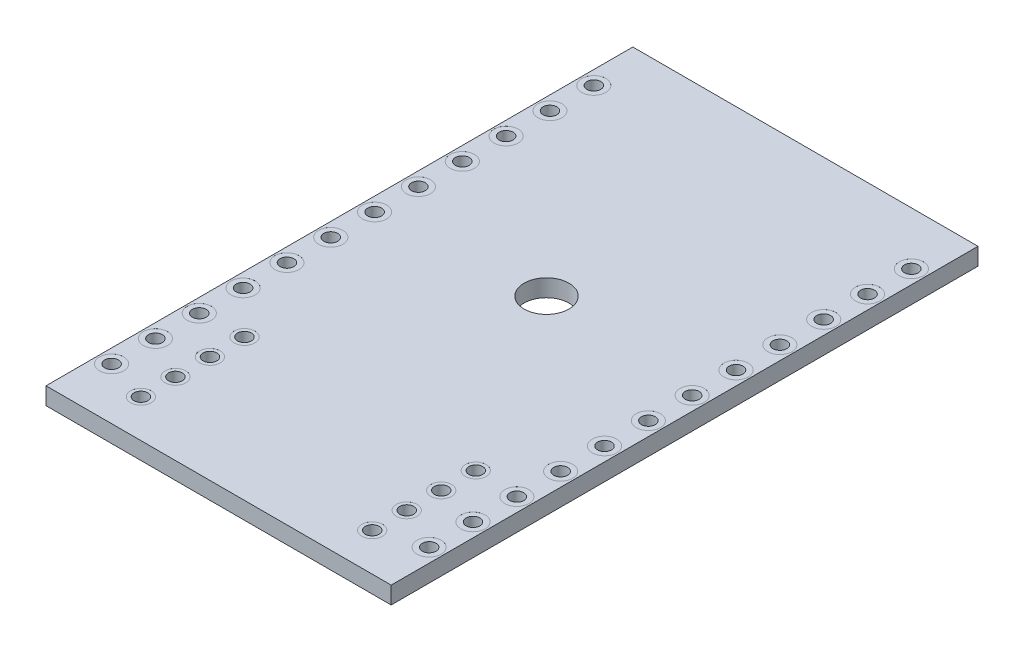
from build123d import *

# Parameters (mm, degrees)
BASES_W                        = 20
BASES_H                        = 34
BASE_DEPTH                     = 0.5
FASTENINGHOLES_R               = 1.3
FASTENINGHOLE_DEPTH            = 2
F_0_8_0_8_DIAMETER_HOLE1_D     = 0.8
SOLDERACCESSCUTS_R             = 0.7
SOLDERACCESSCUT_DEPTH          = 0.001
HOLESACHORZLP_COUNT            = 12
HOLESACHORZLP_PITCH            = 2.54
HOLESACHORZLP_COPY_1_SKETCH_R  = 0.7
HOLESACHORZLP_COPY_1_DEPTH     = 0.001
HOLESACHORZLP_COPY_2_SKETCH_R  = 0.7
HOLESACHORZLP_COPY_2_DEPTH     = 0.001
HOLESACHORZLP_COPY_3_SKETCH_R  = 0.7
HOLESACHORZLP_COPY_3_DEPTH     = 0.001
HOLESACHORZLP_COPY_4_SKETCH_R  = 0.7
HOLESACHORZLP_COPY_4_DEPTH     = 0.001
HOLESACHORZLP_COPY_5_SKETCH_R  = 0.7
HOLESACHORZLP_COPY_5_DEPTH     = 0.001
HOLESACHORZLP_COPY_6_SKETCH_R  = 0.7
HOLESACHORZLP_COPY_6_DEPTH     = 0.001
HOLESACHORZLP_COPY_7_SKETCH_R  = 0.7
HOLESACHORZLP_COPY_7_DEPTH     = 0.001
HOLESACHORZLP_COPY_8_SKETCH_R  = 0.7
HOLESACHORZLP_COPY_8_DEPTH     = 0.001
HOLESACHORZLP_COPY_9_SKETCH_R  = 0.7
HOLESACHORZLP_COPY_9_DEPTH     = 0.001
HOLESACHORZLP_COPY_10_SKETCH_R = 0.7
HOLESACHORZLP_COPY_10_DEPTH    = 0.001
HOLESACHORZLP_COPY_11_SKETCH_R = 0.7
HOLESACHORZLP_COPY_11_DEPTH    = 0.001
HSHM_COPY_1_D                  = 0.8
HSHM_COPY_2_D                  = 0.8
HSHM_COPY_3_D                  = 0.8
HSHM_COPY_4_D                  = 0.8
HSHM_COPY_5_D                  = 0.8
HSHM_COPY_6_D                  = 0.8
HSHM_COPY_7_D                  = 0.8
HSHM_COPY_8_D                  = 0.8
HSHM_COPY_9_D                  = 0.8
HSHM_COPY_10_D                 = 0.8
HSHM_COPY_11_D                 = 0.8
HSHM_COPY_12_SKETCH_R          = 0.7
HSHM_COPY_12_DEPTH             = 0.001
HSHM_COPY_13_SKETCH_R          = 0.7
HSHM_COPY_13_DEPTH             = 0.001
HSHM_COPY_14_SKETCH_R          = 0.7
HSHM_COPY_14_DEPTH             = 0.001
HSHM_COPY_15_SKETCH_R          = 0.7
HSHM_COPY_15_DEPTH             = 0.001
HSHM_COPY_16_SKETCH_R          = 0.7
HSHM_COPY_16_DEPTH             = 0.001
HSHM_COPY_17_SKETCH_R          = 0.7
HSHM_COPY_17_DEPTH             = 0.001
HSHM_COPY_18_SKETCH_R          = 0.7
HSHM_COPY_18_DEPTH             = 0.001
HSHM_COPY_19_SKETCH_R          = 0.7
HSHM_COPY_19_DEPTH             = 0.001
HSHM_COPY_20_SKETCH_R          = 0.7
HSHM_COPY_20_DEPTH             = 0.001
HSHM_COPY_21_SKETCH_R          = 0.7
HSHM_COPY_21_DEPTH             = 0.001
HSHM_COPY_22_SKETCH_R          = 0.7
HSHM_COPY_22_DEPTH             = 0.001
HSHM_COPY_23_SKETCH_R          = 0.7
HSHM_COPY_23_DEPTH             = 0.001
HSHM_COPY_24_SKETCH_R          = 0.7
HSHM_COPY_24_DEPTH             = 0.001
HSHM_COPY_25_SKETCH_R          = 0.7
HSHM_COPY_25_DEPTH             = 0.001
HSHM_COPY_26_SKETCH_R          = 0.7
HSHM_COPY_26_DEPTH             = 0.001
HSHM_COPY_27_SKETCH_R          = 0.7
HSHM_COPY_27_DEPTH             = 0.001
HSHM_COPY_28_SKETCH_R          = 0.7
HSHM_COPY_28_DEPTH             = 0.001
HSHM_COPY_29_SKETCH_R          = 0.7
HSHM_COPY_29_DEPTH             = 0.001
HSHM_COPY_30_SKETCH_R          = 0.7
HSHM_COPY_30_DEPTH             = 0.001
HSHM_COPY_31_SKETCH_R          = 0.7
HSHM_COPY_31_DEPTH             = 0.001
HSHM_COPY_32_SKETCH_R          = 0.7
HSHM_COPY_32_DEPTH             = 0.001
HSHM_COPY_33_SKETCH_R          = 0.7
HSHM_COPY_33_DEPTH             = 0.001
HSHM_COPY_34_SKETCH_R          = 0.7
HSHM_COPY_34_DEPTH             = 0.001
GNDPINS_R                      = 0.4
GNDPIN_DEPTH                   = 2
GPSACS_R                       = 0.6
GPSAC_DEPTH                    = 0.001
GPLP_COUNT                     = 4
GPLP_PITCH                     = 2
GPLP_COPY_1_SKETCH_R           = 0.6
GPLP_COPY_1_DEPTH              = 0.001
GPLP_COPY_2_SKETCH_R           = 0.6
GPLP_COPY_2_DEPTH              = 0.001
GPLP_COPY_3_SKETCH_R           = 0.6
GPLP_COPY_3_DEPTH              = 0.001
GPHM_COPY_1_SKETCH_R           = 0.4
GPHM_COPY_1_DEPTH              = 2
GPHM_COPY_2_SKETCH_R           = 0.4
GPHM_COPY_2_DEPTH              = 2
GPHM_COPY_3_SKETCH_R           = 0.4
GPHM_COPY_3_DEPTH              = 2
GPHM_COPY_4_SKETCH_R           = 0.6
GPHM_COPY_4_DEPTH              = 0.001
GPHM_COPY_5_SKETCH_R           = 0.6
GPHM_COPY_5_DEPTH              = 0.001
GPHM_COPY_6_SKETCH_R           = 0.6
GPHM_COPY_6_DEPTH              = 0.001
GPHM_COPY_7_SKETCH_R           = 0.6
GPHM_COPY_7_DEPTH              = 0.001
GPHM_COPY_8_SKETCH_R           = 0.6
GPHM_COPY_8_DEPTH              = 0.001
GPHM_COPY_9_SKETCH_R           = 0.6
GPHM_COPY_9_DEPTH              = 0.001
GPHM_COPY_10_SKETCH_R          = 0.6
GPHM_COPY_10_DEPTH             = 0.001


with BuildPart() as part:
    # BaseS → Base (new body, symmetric)
    with BuildSketch(Plane(origin=(0, 0, 0), x_dir=(1, 0, 0), z_dir=(0, 1, 0))):
        Rectangle(BASES_W, BASES_H)
    extrude(amount=BASE_DEPTH, both=True)

    # FasteningHoleS → FasteningHole (cut, through all)
    with BuildSketch(Plane(origin=(0, 0.5, 0), x_dir=(1, 0, 0), z_dir=(0, 1, 0))):
        with Locations((0, 2)):
            Circle(FASTENINGHOLES_R)
    extrude(amount=-FASTENINGHOLE_DEPTH, mode=Mode.SUBTRACT)

    # Ø0.8 (0.8) Diameter Hole1 (through all)
    with Locations(Plane(origin=(0, 0.5, 0), x_dir=(1, 0, 0), z_dir=(0, 1, 0))):
        with Locations((-9.2, -14)):
            f_0_8_0_8_diameter_hole1 = Hole(F_0_8_0_8_DIAMETER_HOLE1_D / 2)

    # SolderAccessCutS → SolderAccessCut (cut)
    with BuildSketch(Plane(origin=(0, 0.5, 0), x_dir=(1, 0, 0), z_dir=(0, 1, 0))):
        with Locations((-9.2, -14)):
            Circle(SOLDERACCESSCUTS_R)
    solderaccesscut = extrude(amount=-SOLDERACCESSCUT_DEPTH, mode=Mode.SUBTRACT)

    # SACVM: SolderAccessCut across plane
    add(solderaccesscut.mirror(Plane.ZX), mode=Mode.SUBTRACT)

    # HoleSACHorzLP: Ø0.8 (0.8) Diameter Hole1, SolderAccessCut ×12
    with Locations(*[(0, 0, -i * HOLESACHORZLP_PITCH) for i in range(1, HOLESACHORZLP_COUNT)]):
        add(f_0_8_0_8_diameter_hole1, mode=Mode.SUBTRACT)
        add(solderaccesscut, mode=Mode.SUBTRACT)

    # HoleSACHorzLP copy 1 sketch → HoleSACHorzLP copy 1 (cut)
    with BuildSketch(Plane(origin=(0, -0.5, -2.54), x_dir=(1, 0, 0), z_dir=(0, -1, 0))):
        with Locations((-9.2, 14)):
            Circle(HOLESACHORZLP_COPY_1_SKETCH_R)
    extrude(amount=-HOLESACHORZLP_COPY_1_DEPTH, mode=Mode.SUBTRACT)

    # HoleSACHorzLP copy 2 sketch → HoleSACHorzLP copy 2 (cut)
    with BuildSketch(Plane(origin=(0, -0.5, -5.08), x_dir=(1, 0, 0), z_dir=(0, -1, 0))):
        with Locations((-9.2, 14)):
            Circle(HOLESACHORZLP_COPY_2_SKETCH_R)
    extrude(amount=-HOLESACHORZLP_COPY_2_DEPTH, mode=Mode.SUBTRACT)

    # HoleSACHorzLP copy 3 sketch → HoleSACHorzLP copy 3 (cut)
    with BuildSketch(Plane(origin=(0, -0.5, -7.62), x_dir=(1, 0, 0), z_dir=(0, -1, 0))):
        with Locations((-9.2, 14)):
            Circle(HOLESACHORZLP_COPY_3_SKETCH_R)
    extrude(amount=-HOLESACHORZLP_COPY_3_DEPTH, mode=Mode.SUBTRACT)

    # HoleSACHorzLP copy 4 sketch → HoleSACHorzLP copy 4 (cut)
    with BuildSketch(Plane(origin=(0, -0.5, -10.16), x_dir=(1, 0, 0), z_dir=(0, -1, 0))):
        with Locations((-9.2, 14)):
            Circle(HOLESACHORZLP_COPY_4_SKETCH_R)
    extrude(amount=-HOLESACHORZLP_COPY_4_DEPTH, mode=Mode.SUBTRACT)

    # HoleSACHorzLP copy 5 sketch → HoleSACHorzLP copy 5 (cut)
    with BuildSketch(Plane(origin=(0, -0.5, -12.7), x_dir=(1, 0, 0), z_dir=(0, -1, 0))):
        with Locations((-9.2, 14)):
            Circle(HOLESACHORZLP_COPY_5_SKETCH_R)
    extrude(amount=-HOLESACHORZLP_COPY_5_DEPTH, mode=Mode.SUBTRACT)

    # HoleSACHorzLP copy 6 sketch → HoleSACHorzLP copy 6 (cut)
    with BuildSketch(Plane(origin=(0, -0.5, -15.24), x_dir=(1, 0, 0), z_dir=(0, -1, 0))):
        with Locations((-9.2, 14)):
            Circle(HOLESACHORZLP_COPY_6_SKETCH_R)
    extrude(amount=-HOLESACHORZLP_COPY_6_DEPTH, mode=Mode.SUBTRACT)

    # HoleSACHorzLP copy 7 sketch → HoleSACHorzLP copy 7 (cut)
    with BuildSketch(Plane(origin=(0, -0.5, -17.78), x_dir=(1, 0, 0), z_dir=(0, -1, 0))):
        with Locations((-9.2, 14)):
            Circle(HOLESACHORZLP_COPY_7_SKETCH_R)
    extrude(amount=-HOLESACHORZLP_COPY_7_DEPTH, mode=Mode.SUBTRACT)

    # HoleSACHorzLP copy 8 sketch → HoleSACHorzLP copy 8 (cut)
    with BuildSketch(Plane(origin=(0, -0.5, -20.32), x_dir=(1, 0, 0), z_dir=(0, -1, 0))):
        with Locations((-9.2, 14)):
            Circle(HOLESACHORZLP_COPY_8_SKETCH_R)
    extrude(amount=-HOLESACHORZLP_COPY_8_DEPTH, mode=Mode.SUBTRACT)

    # HoleSACHorzLP copy 9 sketch → HoleSACHorzLP copy 9 (cut)
    with BuildSketch(Plane(origin=(0, -0.5, -22.86), x_dir=(1, 0, 0), z_dir=(0, -1, 0))):
        with Locations((-9.2, 14)):
            Circle(HOLESACHORZLP_COPY_9_SKETCH_R)
    extrude(amount=-HOLESACHORZLP_COPY_9_DEPTH, mode=Mode.SUBTRACT)

    # HoleSACHorzLP copy 10 sketch → HoleSACHorzLP copy 10 (cut)
    with BuildSketch(Plane(origin=(0, -0.5, -25.4), x_dir=(1, 0, 0), z_dir=(0, -1, 0))):
        with Locations((-9.2, 14)):
            Circle(HOLESACHORZLP_COPY_10_SKETCH_R)
    extrude(amount=-HOLESACHORZLP_COPY_10_DEPTH, mode=Mode.SUBTRACT)

    # HoleSACHorzLP copy 11 sketch → HoleSACHorzLP copy 11 (cut)
    with BuildSketch(Plane(origin=(0, -0.5, -27.94), x_dir=(1, 0, 0), z_dir=(0, -1, 0))):
        with Locations((-9.2, 14)):
            Circle(HOLESACHORZLP_COPY_11_SKETCH_R)
    extrude(amount=-HOLESACHORZLP_COPY_11_DEPTH, mode=Mode.SUBTRACT)

    # HSHM: Ø0.8 (0.8) Diameter Hole1, SolderAccessCut across plane
    add(f_0_8_0_8_diameter_hole1.mirror(Plane(origin=(0, 0, 0), x_dir=(0, 0, 1), z_dir=(1, 0, 0))), mode=Mode.SUBTRACT)
    add(solderaccesscut.mirror(Plane(origin=(0, 0, 0), x_dir=(0, 0, 1), z_dir=(1, 0, 0))), mode=Mode.SUBTRACT)

    # HSHM copy 1 (through all)
    with Locations(Plane(origin=(0, 0.5, -2.54), x_dir=(-1, 0, 0), z_dir=(0, 1, 0))):
        with Locations((-9.2, 14)):
            Hole(HSHM_COPY_1_D / 2)

    # HSHM copy 2 (through all)
    with Locations(Plane(origin=(0, 0.5, -5.08), x_dir=(-1, 0, 0), z_dir=(0, 1, 0))):
        with Locations((-9.2, 14)):
            Hole(HSHM_COPY_2_D / 2)

    # HSHM copy 3 (through all)
    with Locations(Plane(origin=(0, 0.5, -7.62), x_dir=(-1, 0, 0), z_dir=(0, 1, 0))):
        with Locations((-9.2, 14)):
            Hole(HSHM_COPY_3_D / 2)

    # HSHM copy 4 (through all)
    with Locations(Plane(origin=(0, 0.5, -10.16), x_dir=(-1, 0, 0), z_dir=(0, 1, 0))):
        with Locations((-9.2, 14)):
            Hole(HSHM_COPY_4_D / 2)

    # HSHM copy 5 (through all)
    with Locations(Plane(origin=(0, 0.5, -12.7), x_dir=(-1, 0, 0), z_dir=(0, 1, 0))):
        with Locations((-9.2, 14)):
            Hole(HSHM_COPY_5_D / 2)

    # HSHM copy 6 (through all)
    with Locations(Plane(origin=(0, 0.5, -15.24), x_dir=(-1, 0, 0), z_dir=(0, 1, 0))):
        with Locations((-9.2, 14)):
            Hole(HSHM_COPY_6_D / 2)

    # HSHM copy 7 (through all)
    with Locations(Plane(origin=(0, 0.5, -17.78), x_dir=(-1, 0, 0), z_dir=(0, 1, 0))):
        with Locations((-9.2, 14)):
            Hole(HSHM_COPY_7_D / 2)

    # HSHM copy 8 (through all)
    with Locations(Plane(origin=(0, 0.5, -20.32), x_dir=(-1, 0, 0), z_dir=(0, 1, 0))):
        with Locations((-9.2, 14)):
            Hole(HSHM_COPY_8_D / 2)

    # HSHM copy 9 (through all)
    with Locations(Plane(origin=(0, 0.5, -22.86), x_dir=(-1, 0, 0), z_dir=(0, 1, 0))):
        with Locations((-9.2, 14)):
            Hole(HSHM_COPY_9_D / 2)

    # HSHM copy 10 (through all)
    with Locations(Plane(origin=(0, 0.5, -25.4), x_dir=(-1, 0, 0), z_dir=(0, 1, 0))):
        with Locations((-9.2, 14)):
            Hole(HSHM_COPY_10_D / 2)

    # HSHM copy 11 (through all)
    with Locations(Plane(origin=(0, 0.5, -27.94), x_dir=(-1, 0, 0), z_dir=(0, 1, 0))):
        with Locations((-9.2, 14)):
            Hole(HSHM_COPY_11_D / 2)

    # HSHM copy 12 sketch → HSHM copy 12 (cut)
    with BuildSketch(Plane(origin=(0, 0.5, -2.54), x_dir=(-1, 0, 0), z_dir=(0, 1, 0))):
        with Locations((-9.2, 14)):
            Circle(HSHM_COPY_12_SKETCH_R)
    extrude(amount=-HSHM_COPY_12_DEPTH, mode=Mode.SUBTRACT)

    # HSHM copy 13 sketch → HSHM copy 13 (cut)
    with BuildSketch(Plane(origin=(0, 0.5, -5.08), x_dir=(-1, 0, 0), z_dir=(0, 1, 0))):
        with Locations((-9.2, 14)):
            Circle(HSHM_COPY_13_SKETCH_R)
    extrude(amount=-HSHM_COPY_13_DEPTH, mode=Mode.SUBTRACT)

    # HSHM copy 14 sketch → HSHM copy 14 (cut)
    with BuildSketch(Plane(origin=(0, 0.5, -7.62), x_dir=(-1, 0, 0), z_dir=(0, 1, 0))):
        with Locations((-9.2, 14)):
            Circle(HSHM_COPY_14_SKETCH_R)
    extrude(amount=-HSHM_COPY_14_DEPTH, mode=Mode.SUBTRACT)

    # HSHM copy 15 sketch → HSHM copy 15 (cut)
    with BuildSketch(Plane(origin=(0, 0.5, -10.16), x_dir=(-1, 0, 0), z_dir=(0, 1, 0))):
        with Locations((-9.2, 14)):
            Circle(HSHM_COPY_15_SKETCH_R)
    extrude(amount=-HSHM_COPY_15_DEPTH, mode=Mode.SUBTRACT)

    # HSHM copy 16 sketch → HSHM copy 16 (cut)
    with BuildSketch(Plane(origin=(0, 0.5, -12.7), x_dir=(-1, 0, 0), z_dir=(0, 1, 0))):
        with Locations((-9.2, 14)):
            Circle(HSHM_COPY_16_SKETCH_R)
    extrude(amount=-HSHM_COPY_16_DEPTH, mode=Mode.SUBTRACT)

    # HSHM copy 17 sketch → HSHM copy 17 (cut)
    with BuildSketch(Plane(origin=(0, 0.5, -15.24), x_dir=(-1, 0, 0), z_dir=(0, 1, 0))):
        with Locations((-9.2, 14)):
            Circle(HSHM_COPY_17_SKETCH_R)
    extrude(amount=-HSHM_COPY_17_DEPTH, mode=Mode.SUBTRACT)

    # HSHM copy 18 sketch → HSHM copy 18 (cut)
    with BuildSketch(Plane(origin=(0, 0.5, -17.78), x_dir=(-1, 0, 0), z_dir=(0, 1, 0))):
        with Locations((-9.2, 14)):
            Circle(HSHM_COPY_18_SKETCH_R)
    extrude(amount=-HSHM_COPY_18_DEPTH, mode=Mode.SUBTRACT)

    # HSHM copy 19 sketch → HSHM copy 19 (cut)
    with BuildSketch(Plane(origin=(0, 0.5, -20.32), x_dir=(-1, 0, 0), z_dir=(0, 1, 0))):
        with Locations((-9.2, 14)):
            Circle(HSHM_COPY_19_SKETCH_R)
    extrude(amount=-HSHM_COPY_19_DEPTH, mode=Mode.SUBTRACT)

    # HSHM copy 20 sketch → HSHM copy 20 (cut)
    with BuildSketch(Plane(origin=(0, 0.5, -22.86), x_dir=(-1, 0, 0), z_dir=(0, 1, 0))):
        with Locations((-9.2, 14)):
            Circle(HSHM_COPY_20_SKETCH_R)
    extrude(amount=-HSHM_COPY_20_DEPTH, mode=Mode.SUBTRACT)

    # HSHM copy 21 sketch → HSHM copy 21 (cut)
    with BuildSketch(Plane(origin=(0, 0.5, -25.4), x_dir=(-1, 0, 0), z_dir=(0, 1, 0))):
        with Locations((-9.2, 14)):
            Circle(HSHM_COPY_21_SKETCH_R)
    extrude(amount=-HSHM_COPY_21_DEPTH, mode=Mode.SUBTRACT)

    # HSHM copy 22 sketch → HSHM copy 22 (cut)
    with BuildSketch(Plane(origin=(0, 0.5, -27.94), x_dir=(-1, 0, 0), z_dir=(0, 1, 0))):
        with Locations((-9.2, 14)):
            Circle(HSHM_COPY_22_SKETCH_R)
    extrude(amount=-HSHM_COPY_22_DEPTH, mode=Mode.SUBTRACT)

    # HSHM copy 23 sketch → HSHM copy 23 (cut)
    with BuildSketch(Plane(origin=(0, -0.5, -2.54), x_dir=(-1, 0, 0), z_dir=(0, -1, 0))):
        with Locations((-9.2, -14)):
            Circle(HSHM_COPY_23_SKETCH_R)
    extrude(amount=-HSHM_COPY_23_DEPTH, mode=Mode.SUBTRACT)

    # HSHM copy 24 sketch → HSHM copy 24 (cut)
    with BuildSketch(Plane(origin=(0, -0.5, -5.08), x_dir=(-1, 0, 0), z_dir=(0, -1, 0))):
        with Locations((-9.2, -14)):
            Circle(HSHM_COPY_24_SKETCH_R)
    extrude(amount=-HSHM_COPY_24_DEPTH, mode=Mode.SUBTRACT)

    # HSHM copy 25 sketch → HSHM copy 25 (cut)
    with BuildSketch(Plane(origin=(0, -0.5, -7.62), x_dir=(-1, 0, 0), z_dir=(0, -1, 0))):
        with Locations((-9.2, -14)):
            Circle(HSHM_COPY_25_SKETCH_R)
    extrude(amount=-HSHM_COPY_25_DEPTH, mode=Mode.SUBTRACT)

    # HSHM copy 26 sketch → HSHM copy 26 (cut)
    with BuildSketch(Plane(origin=(0, -0.5, -10.16), x_dir=(-1, 0, 0), z_dir=(0, -1, 0))):
        with Locations((-9.2, -14)):
            Circle(HSHM_COPY_26_SKETCH_R)
    extrude(amount=-HSHM_COPY_26_DEPTH, mode=Mode.SUBTRACT)

    # HSHM copy 27 sketch → HSHM copy 27 (cut)
    with BuildSketch(Plane(origin=(0, -0.5, -12.7), x_dir=(-1, 0, 0), z_dir=(0, -1, 0))):
        with Locations((-9.2, -14)):
            Circle(HSHM_COPY_27_SKETCH_R)
    extrude(amount=-HSHM_COPY_27_DEPTH, mode=Mode.SUBTRACT)

    # HSHM copy 28 sketch → HSHM copy 28 (cut)
    with BuildSketch(Plane(origin=(0, -0.5, -15.24), x_dir=(-1, 0, 0), z_dir=(0, -1, 0))):
        with Locations((-9.2, -14)):
            Circle(HSHM_COPY_28_SKETCH_R)
    extrude(amount=-HSHM_COPY_28_DEPTH, mode=Mode.SUBTRACT)

    # HSHM copy 29 sketch → HSHM copy 29 (cut)
    with BuildSketch(Plane(origin=(0, -0.5, -17.78), x_dir=(-1, 0, 0), z_dir=(0, -1, 0))):
        with Locations((-9.2, -14)):
            Circle(HSHM_COPY_29_SKETCH_R)
    extrude(amount=-HSHM_COPY_29_DEPTH, mode=Mode.SUBTRACT)

    # HSHM copy 30 sketch → HSHM copy 30 (cut)
    with BuildSketch(Plane(origin=(0, -0.5, -20.32), x_dir=(-1, 0, 0), z_dir=(0, -1, 0))):
        with Locations((-9.2, -14)):
            Circle(HSHM_COPY_30_SKETCH_R)
    extrude(amount=-HSHM_COPY_30_DEPTH, mode=Mode.SUBTRACT)

    # HSHM copy 31 sketch → HSHM copy 31 (cut)
    with BuildSketch(Plane(origin=(0, -0.5, -22.86), x_dir=(-1, 0, 0), z_dir=(0, -1, 0))):
        with Locations((-9.2, -14)):
            Circle(HSHM_COPY_31_SKETCH_R)
    extrude(amount=-HSHM_COPY_31_DEPTH, mode=Mode.SUBTRACT)

    # HSHM copy 32 sketch → HSHM copy 32 (cut)
    with BuildSketch(Plane(origin=(0, -0.5, -25.4), x_dir=(-1, 0, 0), z_dir=(0, -1, 0))):
        with Locations((-9.2, -14)):
            Circle(HSHM_COPY_32_SKETCH_R)
    extrude(amount=-HSHM_COPY_32_DEPTH, mode=Mode.SUBTRACT)

    # HSHM copy 33 sketch → HSHM copy 33 (cut)
    with BuildSketch(Plane(origin=(0, -0.5, -27.94), x_dir=(-1, 0, 0), z_dir=(0, -1, 0))):
        with Locations((-9.2, -14)):
            Circle(HSHM_COPY_33_SKETCH_R)
    extrude(amount=-HSHM_COPY_33_DEPTH, mode=Mode.SUBTRACT)

    # HSHM copy 34 sketch → HSHM copy 34 (cut)
    with BuildSketch(Plane(origin=(0, -0.5, 0), x_dir=(-1, 0, 0), z_dir=(0, -1, 0))):
        with Locations((-9.2, -14)):
            Circle(HSHM_COPY_34_SKETCH_R)
    extrude(amount=-HSHM_COPY_34_DEPTH, mode=Mode.SUBTRACT)

    # GndPinS → GndPin (cut, through all)
    with BuildSketch(Plane(origin=(0, 0.5, 0), x_dir=(1, 0, 0), z_dir=(0, 1, 0))):
        with Locations((6.7, -14.8)):
            Circle(GNDPINS_R)
    gndpin = extrude(amount=-GNDPIN_DEPTH, mode=Mode.SUBTRACT)

    # GPSACS → GPSAC (cut)
    with BuildSketch(Plane(origin=(0, 0.5, 0), x_dir=(1, 0, 0), z_dir=(0, 1, 0))):
        with Locations((6.7, -14.8)):
            Circle(GPSACS_R)
    gpsac = extrude(amount=-GPSAC_DEPTH, mode=Mode.SUBTRACT)

    # GPSACVM: GPSAC across plane
    add(gpsac.mirror(Plane.ZX), mode=Mode.SUBTRACT)

    # GPLP: GndPin, GPSAC ×4
    with Locations(*[(0, 0, -i * GPLP_PITCH) for i in range(1, GPLP_COUNT)]):
        add(gndpin, mode=Mode.SUBTRACT)
        add(gpsac, mode=Mode.SUBTRACT)

    # GPLP copy 1 sketch → GPLP copy 1 (cut)
    with BuildSketch(Plane(origin=(0, -0.5, -2), x_dir=(1, 0, 0), z_dir=(0, -1, 0))):
        with Locations((6.7, 14.8)):
            Circle(GPLP_COPY_1_SKETCH_R)
    extrude(amount=-GPLP_COPY_1_DEPTH, mode=Mode.SUBTRACT)

    # GPLP copy 2 sketch → GPLP copy 2 (cut)
    with BuildSketch(Plane(origin=(0, -0.5, -4), x_dir=(1, 0, 0), z_dir=(0, -1, 0))):
        with Locations((6.7, 14.8)):
            Circle(GPLP_COPY_2_SKETCH_R)
    extrude(amount=-GPLP_COPY_2_DEPTH, mode=Mode.SUBTRACT)

    # GPLP copy 3 sketch → GPLP copy 3 (cut)
    with BuildSketch(Plane(origin=(0, -0.5, -6), x_dir=(1, 0, 0), z_dir=(0, -1, 0))):
        with Locations((6.7, 14.8)):
            Circle(GPLP_COPY_3_SKETCH_R)
    extrude(amount=-GPLP_COPY_3_DEPTH, mode=Mode.SUBTRACT)

    # GPHM: GPSAC, GndPin across plane
    add(gpsac.mirror(Plane(origin=(0, 0, 0), x_dir=(0, 0, 1), z_dir=(1, 0, 0))), mode=Mode.SUBTRACT)
    add(gndpin.mirror(Plane(origin=(0, 0, 0), x_dir=(0, 0, 1), z_dir=(1, 0, 0))), mode=Mode.SUBTRACT)

    # GPHM copy 1 sketch → GPHM copy 1 (cut, through all)
    with BuildSketch(Plane(origin=(0, 0.5, -2), x_dir=(-1, 0, 0), z_dir=(0, 1, 0))):
        with Locations((6.7, 14.8)):
            Circle(GPHM_COPY_1_SKETCH_R)
    extrude(amount=-GPHM_COPY_1_DEPTH, mode=Mode.SUBTRACT)

    # GPHM copy 2 sketch → GPHM copy 2 (cut, through all)
    with BuildSketch(Plane(origin=(0, 0.5, -4), x_dir=(-1, 0, 0), z_dir=(0, 1, 0))):
        with Locations((6.7, 14.8)):
            Circle(GPHM_COPY_2_SKETCH_R)
    extrude(amount=-GPHM_COPY_2_DEPTH, mode=Mode.SUBTRACT)

    # GPHM copy 3 sketch → GPHM copy 3 (cut, through all)
    with BuildSketch(Plane(origin=(0, 0.5, -6), x_dir=(-1, 0, 0), z_dir=(0, 1, 0))):
        with Locations((6.7, 14.8)):
            Circle(GPHM_COPY_3_SKETCH_R)
    extrude(amount=-GPHM_COPY_3_DEPTH, mode=Mode.SUBTRACT)

    # GPHM copy 4 sketch → GPHM copy 4 (cut)
    with BuildSketch(Plane(origin=(0, 0.5, -2), x_dir=(-1, 0, 0), z_dir=(0, 1, 0))):
        with Locations((6.7, 14.8)):
            Circle(GPHM_COPY_4_SKETCH_R)
    extrude(amount=-GPHM_COPY_4_DEPTH, mode=Mode.SUBTRACT)

    # GPHM copy 5 sketch → GPHM copy 5 (cut)
    with BuildSketch(Plane(origin=(0, 0.5, -4), x_dir=(-1, 0, 0), z_dir=(0, 1, 0))):
        with Locations((6.7, 14.8)):
            Circle(GPHM_COPY_5_SKETCH_R)
    extrude(amount=-GPHM_COPY_5_DEPTH, mode=Mode.SUBTRACT)

    # GPHM copy 6 sketch → GPHM copy 6 (cut)
    with BuildSketch(Plane(origin=(0, 0.5, -6), x_dir=(-1, 0, 0), z_dir=(0, 1, 0))):
        with Locations((6.7, 14.8)):
            Circle(GPHM_COPY_6_SKETCH_R)
    extrude(amount=-GPHM_COPY_6_DEPTH, mode=Mode.SUBTRACT)

    # GPHM copy 7 sketch → GPHM copy 7 (cut)
    with BuildSketch(Plane(origin=(0, -0.5, -2), x_dir=(-1, 0, 0), z_dir=(0, -1, 0))):
        with Locations((6.7, -14.8)):
            Circle(GPHM_COPY_7_SKETCH_R)
    extrude(amount=-GPHM_COPY_7_DEPTH, mode=Mode.SUBTRACT)

    # GPHM copy 8 sketch → GPHM copy 8 (cut)
    with BuildSketch(Plane(origin=(0, -0.5, -4), x_dir=(-1, 0, 0), z_dir=(0, -1, 0))):
        with Locations((6.7, -14.8)):
            Circle(GPHM_COPY_8_SKETCH_R)
    extrude(amount=-GPHM_COPY_8_DEPTH, mode=Mode.SUBTRACT)

    # GPHM copy 9 sketch → GPHM copy 9 (cut)
    with BuildSketch(Plane(origin=(0, -0.5, -6), x_dir=(-1, 0, 0), z_dir=(0, -1, 0))):
        with Locations((6.7, -14.8)):
            Circle(GPHM_COPY_9_SKETCH_R)
    extrude(amount=-GPHM_COPY_9_DEPTH, mode=Mode.SUBTRACT)

    # GPHM copy 10 sketch → GPHM copy 10 (cut)
    with BuildSketch(Plane(origin=(0, -0.5, 0), x_dir=(-1, 0, 0), z_dir=(0, -1, 0))):
        with Locations((6.7, -14.8)):
            Circle(GPHM_COPY_10_SKETCH_R)
    extrude(amount=-GPHM_COPY_10_DEPTH, mode=Mode.SUBTRACT)


solid = part.part
